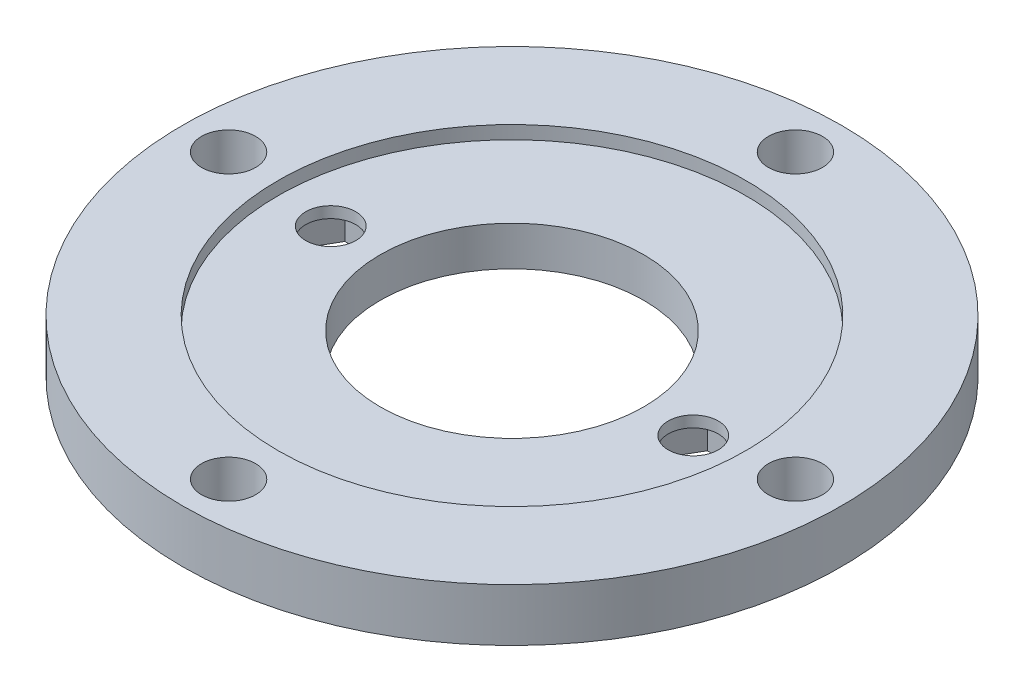
from build123d import *

# Parameters (mm, degrees)
SKETCH1_R               = 50
SKETCH1_R_2             = 35.5
BOSS_EXTRUDE1_DEPTH     = 8
SKETCH2_R               = 4.1
CUT_EXTRUDE1_DEPTH      = 1
CUT_EXTRUDE1_DEPTH_BACK = 9
SKETCH3_R               = 35.5
SKETCH3_R_2             = 20
BOSS_EXTRUDE2_DEPTH     = 6
CUT_EXTRUDE2_START      = -6
CUT_EXTRUDE2_DEPTH      = 4.3
SKETCH5_R               = 3.8
CUT_EXTRUDE3_DEPTH      = 7
CUT_EXTRUDE3_DEPTH_BACK = 3


with BuildPart() as part:
    # Sketch1 → Boss-Extrude1 (new body)
    with BuildSketch(Plane(origin=(0, 0, 0), x_dir=(1, 0, 0), z_dir=(0, 1, 0))):
        Circle(SKETCH1_R)
        Circle(SKETCH1_R_2, mode=Mode.SUBTRACT)
    extrude(amount=BOSS_EXTRUDE1_DEPTH)

    # Sketch2 → Cut-Extrude1 (cut, two sides)
    with BuildSketch(Plane(origin=(0, 8, 0), x_dir=(1, 0, 0), z_dir=(0, 1, 0))) as cut_extrude1_sk:
        with Locations((0, -43)):
            Circle(SKETCH2_R)
        with Locations((-43, 0)):
            Circle(SKETCH2_R)
        with Locations((0, 43)):
            Circle(SKETCH2_R)
        with Locations((43, 0)):
            Circle(SKETCH2_R)
    extrude(amount=CUT_EXTRUDE1_DEPTH, mode=Mode.SUBTRACT)
    extrude(cut_extrude1_sk.sketch, amount=-CUT_EXTRUDE1_DEPTH_BACK, mode=Mode.SUBTRACT)

    # Sketch3 → Boss-Extrude2 (add)
    with BuildSketch(Plane(origin=(0, 0, 0), x_dir=(1, 0, 0), z_dir=(0, 1, 0))):
        Circle(SKETCH3_R)
        Circle(SKETCH3_R_2, mode=Mode.SUBTRACT)
    extrude(amount=BOSS_EXTRUDE2_DEPTH)

    # Sketch4 → Cut-Extrude2 (cut)
    with BuildSketch(Plane(origin=(0, 6, 0), x_dir=(1, 0, 0), z_dir=(0, 1, 0)).offset(CUT_EXTRUDE2_START)):
        Polygon((-21.668762281, 0), (-24.584381141, 5.05), (-30.415618859, 5.05), (-33.331237719, 0), (-30.415618859, -5.05), (-24.584381141, -5.05), align=None)
        Polygon((33.331237719, 0), (30.415618859, 5.05), (24.584381141, 5.05), (21.668762281, 0), (24.584381141, -5.05), (30.415618859, -5.05), align=None)
    extrude(amount=CUT_EXTRUDE2_DEPTH, mode=Mode.SUBTRACT)

    # Sketch5 → Cut-Extrude3 (cut, two sides)
    with BuildSketch(Plane(origin=(0, 6, -6), x_dir=(1, 0, 0), z_dir=(0, -1, 0))) as cut_extrude3_sk:
        with Locations((-27.5, 6)):
            Circle(SKETCH5_R)
        with Locations((27.5, 6)):
            Circle(SKETCH5_R)
    extrude(amount=CUT_EXTRUDE3_DEPTH, mode=Mode.SUBTRACT)
    extrude(cut_extrude3_sk.sketch, amount=-CUT_EXTRUDE3_DEPTH_BACK, mode=Mode.SUBTRACT)


solid = part.part
